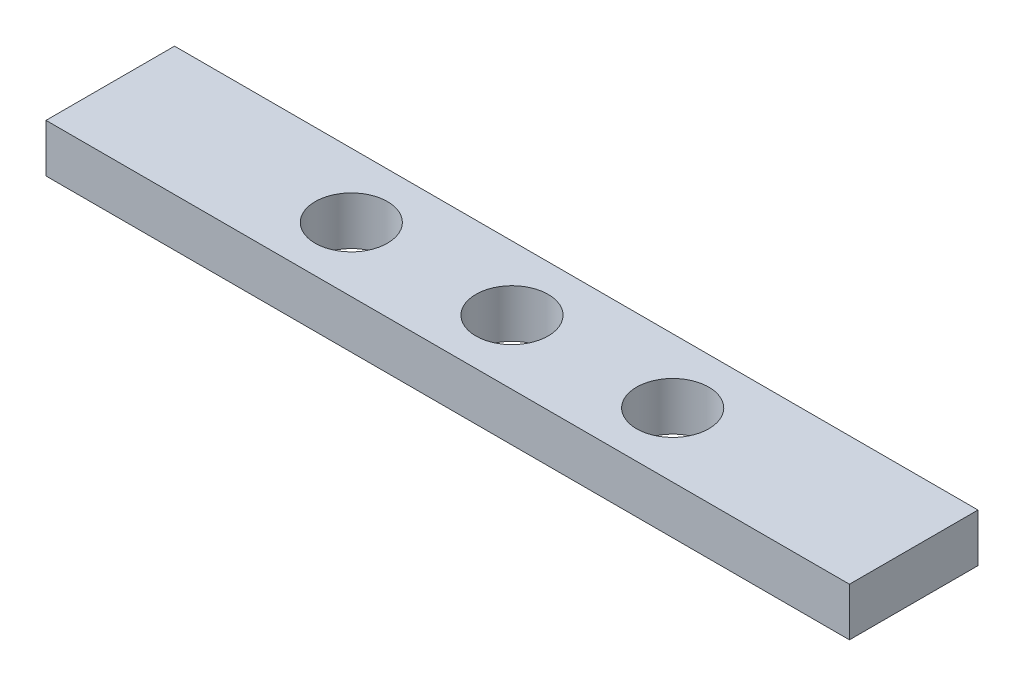
from build123d import *

# Parameters (mm, degrees)
SKETCH1_W                 = 50
SKETCH1_H                 = 8
BOSS_EXTRUDE1_DEPTH       = 3
F_8_CLEARANCE_HOLE1_D     = 4.4958
F_8_CLEARANCE_HOLE1_DEPTH = 17
F_8_CLEARANCE_HOLE1_TIP   = 1.350674586


with BuildPart() as part:
    # Sketch1 → Boss-Extrude1 (new body)
    with BuildSketch(Plane(origin=(0, 0, 0), x_dir=(1, 0, 0), z_dir=(0, 1, 0))):
        with Locations((17.773632998, 0.313559322)):
            Rectangle(SKETCH1_W, SKETCH1_H)
    extrude(amount=BOSS_EXTRUDE1_DEPTH)

    # #8 Clearance Hole1
    with Locations(Plane(origin=(7.773632998, 3, -0.313559322), x_dir=(0, 0, 1), z_dir=(0, 1, 0))):
        with Locations((0, 0), (0, 20), (0, 10)):
            Hole(F_8_CLEARANCE_HOLE1_D / 2, depth=F_8_CLEARANCE_HOLE1_DEPTH)
            with Locations((0, 0, -(F_8_CLEARANCE_HOLE1_DEPTH + F_8_CLEARANCE_HOLE1_TIP / 2))):  # 118° drill point
                Cone(0, F_8_CLEARANCE_HOLE1_D / 2, F_8_CLEARANCE_HOLE1_TIP, mode=Mode.SUBTRACT)


solid = part.part
